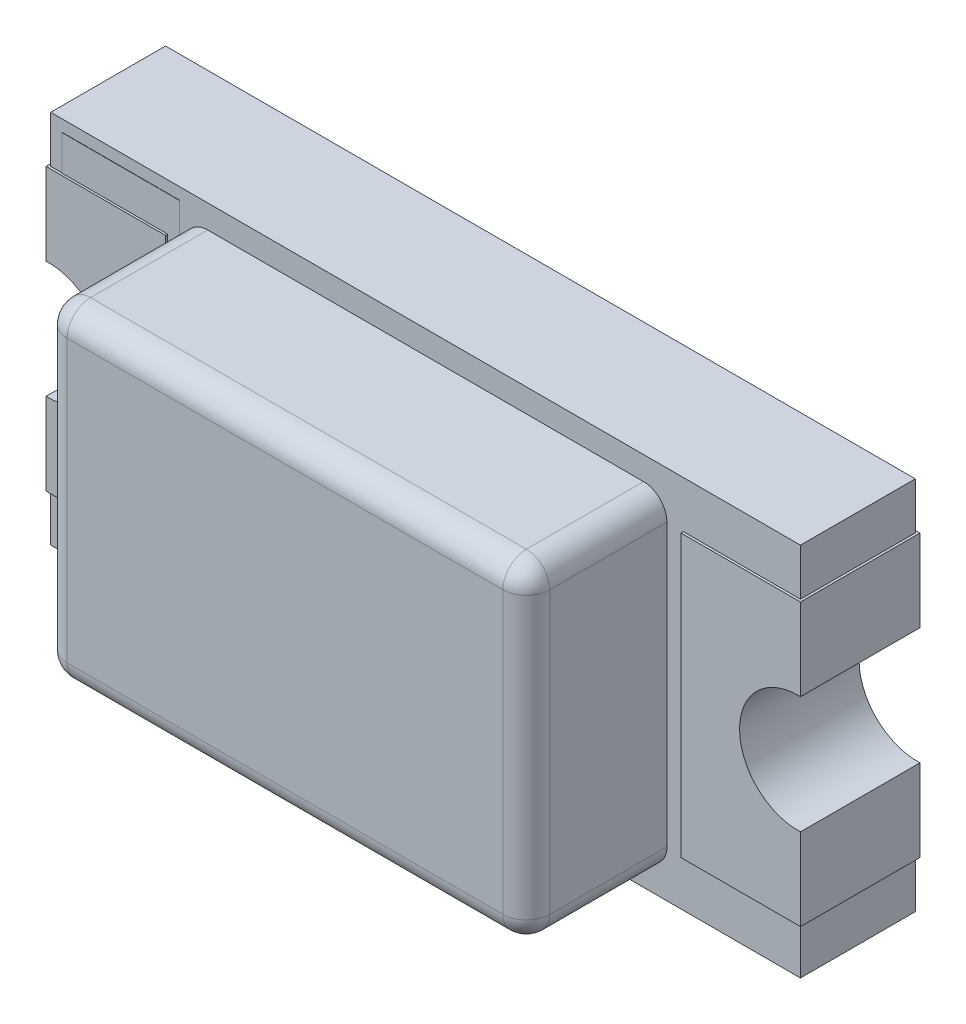
from build123d import *

# Parameters (mm, degrees)
EXTRUDE_START       = 0.01
SKETCH_2_W          = 3.2
SKETCH_2_H          = 1.6
EXTRUDE_1_DEPTH     = 0.49
SKETCH_3_W          = 0.51
SKETCH_3_H          = 1.2
EXTRUDE_2_DEPTH     = 0.51
EXTRUDE_START_2     = 0.5
SKETCH_4_W          = 2.06
SKETCH_4_H          = 1.4
EXTRUDE_3_DEPTH     = 0.6
FILLET_1_R          = 0.1
SKETCH_5_W          = 0.5
SKETCH_5_H          = 1.5
EXTRUDE_4_DEPTH     = 0.001
SKETCH_6_R          = 0.25
CUT_EXTRUDE_2_DEPTH = 0.52


with BuildPart() as part:
    # Эскиз2 → Бобышка-Вытянуть1 (new body)
    with BuildSketch(Plane.XY.offset(EXTRUDE_START)):
        Rectangle(SKETCH_2_W, SKETCH_2_H)
    extrude(amount=EXTRUDE_1_DEPTH)

    # Эскиз3 → Бобышка-Вытянуть2 (add)
    with BuildSketch(Plane.XY):
        with Locations((-1.355, 0)):
            Rectangle(SKETCH_3_W, SKETCH_3_H)
        with Locations((1.355, 0)):
            Rectangle(SKETCH_3_W, SKETCH_3_H)
    extrude(amount=EXTRUDE_2_DEPTH)

    # Эскиз4 → Бобышка-Вытянуть3 (add)
    with BuildSketch(Plane.XY.offset(EXTRUDE_START_2)):
        Rectangle(SKETCH_4_W, SKETCH_4_H)
    extrude(amount=EXTRUDE_3_DEPTH)

    # Скругление1
    fillet_1_edges = [part.edges().sort_by_distance(p)[0] for p in [
        (-1.03, 0.7, 0.8),
        (-1.03, -0.7, 0.8),
        (1.03, -0.7, 0.8),
        (1.03, 0.7, 0.8),
        (-1.03, 0, 1.1),
        (0, -0.7, 1.1),
        (1.03, 0, 1.1),
        (0, 0.7, 1.1),
    ]]
    fillet(fillet_1_edges, radius=FILLET_1_R)

    # Эскиз5 → Бобышка-Вытянуть4 (add)
    with BuildSketch(Plane.XY.offset(0.5)):
        with Locations((-1.3, 0)):
            Rectangle(SKETCH_5_W, SKETCH_5_H)
    extrude(amount=EXTRUDE_4_DEPTH)

    # Эскиз6 → Вырез-Вытянуть2 (cut)
    with BuildSketch(Plane.XY):
        with Locations((-1.6, 0)):
            Circle(SKETCH_6_R)
        with Locations((1.6, 0)):
            Circle(SKETCH_6_R)
    extrude(amount=CUT_EXTRUDE_2_DEPTH, mode=Mode.SUBTRACT)


solid = part.part
